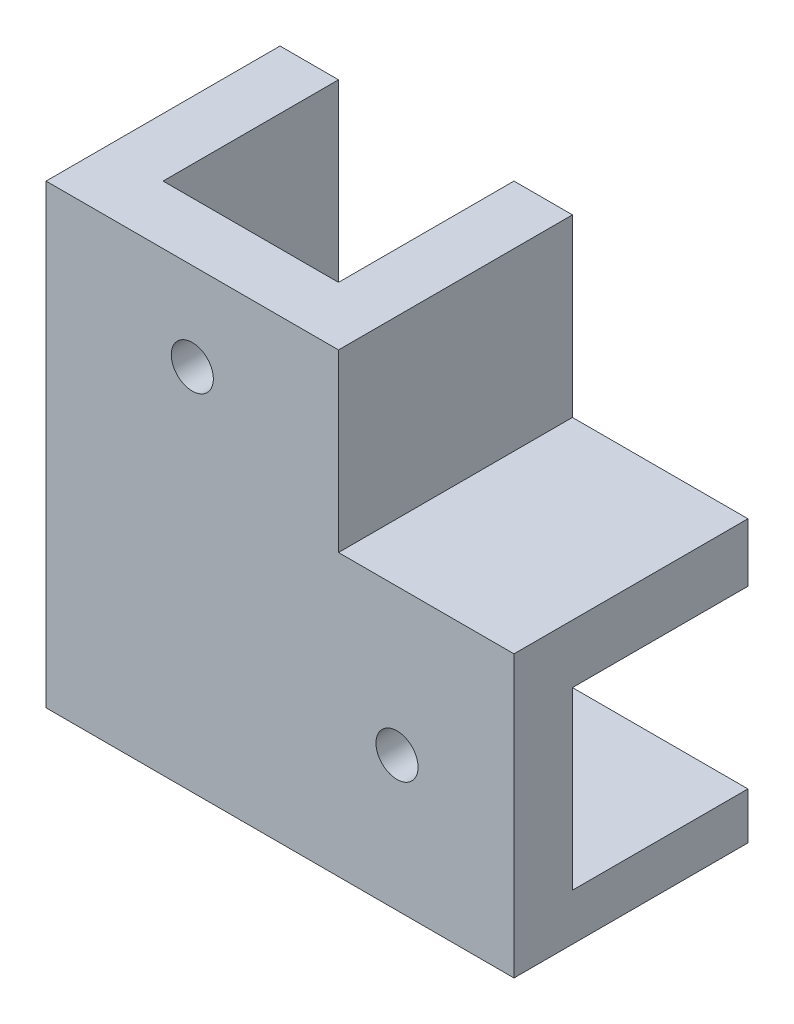
from build123d import *

# Parameters (mm, degrees)
BOSS_EXTRUDE1_DEPTH = 5
BOSS_EXTRUDE2_DEPTH = 15
SKETCH3_W           = 5
SKETCH3_H           = 35
BOSS_EXTRUDE3_DEPTH = 15
SKETCH4_W           = 5
SKETCH4_H           = 35
BOSS_EXTRUDE4_DEPTH = 5
BOSS_EXTRUDE5_DEPTH = 5
SKETCH7_R           = 1.8
CUT_EXTRUDE1_DEPTH  = 6
SKETCH9_W           = 5
SKETCH9_H           = 15
BOSS_EXTRUDE6_DEPTH = 13
BOSS_EXTRUDE7_DEPTH = 4
SKETCH13_R          = 1.5
CUT_EXTRUDE4_DEPTH  = 40


with BuildPart() as part:
    # Sketch1 → Boss-Extrude1 (new body)
    with BuildSketch(Plane.XY):
        Polygon((-7.529880478, -25.806772908), (27.470119522, -25.806772908), (27.470119522, -10.806772908), (7.470119522, -10.806772908), (7.470119522, 9.193227092), (-7.529880478, 9.193227092), align=None)
    extrude(amount=BOSS_EXTRUDE1_DEPTH)



with BuildPart() as body_2:
    # Sketch2 → Boss-Extrude2 (new body)
    with BuildSketch(Plane(origin=(0, 0, 0), x_dir=(-1, 0, 0), z_dir=(0, 0, -1))):
        Polygon((-7.470119522, 9.193227092), (-12.470119522, 9.193227092), (-12.470119522, -5.806772908), (-27.470119522, -5.806772908), (-27.470119522, -10.806772908), (-7.470119522, -10.806772908), align=None)
    extrude(amount=BOSS_EXTRUDE2_DEPTH)


with BuildPart() as body_3:
    # Sketch3 → Boss-Extrude3 (new body)
    with BuildSketch(Plane(origin=(0, 0, 0), x_dir=(-1, 0, 0), z_dir=(0, 0, -1))):
        with Locations((10.029880478, -8.306772908)):
            Rectangle(SKETCH3_W, SKETCH3_H)
    extrude(amount=BOSS_EXTRUDE3_DEPTH)


with BuildPart() as part_1:
    add(part.part)

    add(body_3.part)  # Boss-Extrude4 merges body 3
    # Sketch4 → Boss-Extrude4 (add)
    with BuildSketch(Plane.XY):
        with Locations((-10.029880478, -8.306772908)):
            Rectangle(SKETCH4_W, SKETCH4_H)
    extrude(amount=BOSS_EXTRUDE4_DEPTH)


    add(body_2.part)  # Boss-Extrude5 merges body 2
    # Sketch5 → Boss-Extrude5 (add)
    with BuildSketch(Plane.XY):
        Polygon((7.470119522, 9.193227092), (7.470119522, -10.806772908), (27.470119522, -10.806772908), (27.470119522, -5.806772908), (12.470119522, -5.806772908), (12.470119522, 9.193227092), align=None)
    extrude(amount=BOSS_EXTRUDE5_DEPTH)

    # Sketch7 → Cut-Extrude1 (cut, through all)
    with BuildSketch(Plane(origin=(0, 0, 0), x_dir=(-1, 0, 0), z_dir=(0, 0, -1))):
        with Locations((0.029880478, 1.693227092)):
            Circle(SKETCH7_R)
        with Locations((-17.470119522, -18.306772908)):
            Circle(SKETCH7_R)
    extrude(amount=-CUT_EXTRUDE1_DEPTH, mode=Mode.SUBTRACT)

    # Sketch9 → Boss-Extrude6 (add)
    with BuildSketch(Plane(origin=(0, 0, -15), x_dir=(-1, 0, 0), z_dir=(0, 0, -1))):
        with Locations((10.029880478, -18.306772908)):
            Rectangle(SKETCH9_W, SKETCH9_H)
    extrude(amount=BOSS_EXTRUDE6_DEPTH)

    # Sketch12 → Boss-Extrude7 (add)
    with BuildSketch(Plane.XZ.offset(25.806772908)):
        Polygon((7.470119522, -28), (-12.529880478, -28), (-12.529880478, 5), (7.470119522, 5), (27.470119522, 5), (27.470119522, -15), (7.470119522, -15), align=None)
    extrude(amount=BOSS_EXTRUDE7_DEPTH)

    # Sketch13 → Cut-Extrude4 (cut, through all)
    with BuildSketch(Plane.XZ.offset(29.806772908)):
        with Locations((-0.029880478, -20.5)):
            Circle(SKETCH13_R)
    extrude(amount=-CUT_EXTRUDE4_DEPTH, mode=Mode.SUBTRACT)


solid = part_1.part
